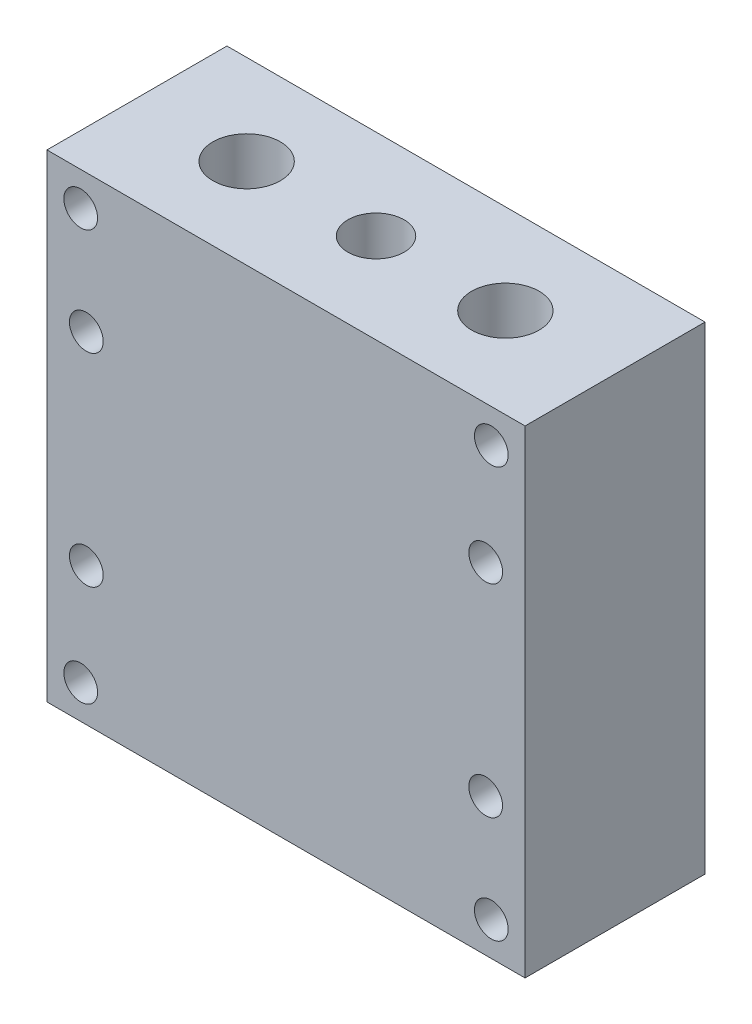
from build123d import *

# Parameters (mm, degrees)
SKETCH1_W           = 85
SKETCH1_H           = 85
BOSS_EXTRUDE1_DEPTH = 32
SKETCH2_R           = 3
CUT_EXTRUDE1_DEPTH  = 33
SKETCH3_R           = 5
SKETCH3_R_2         = 6
CUT_EXTRUDE2_DEPTH  = 86
SKETCH4_R           = 3
CUT_EXTRUDE3_DEPTH  = 33


with BuildPart() as part:
    # Sketch1 → Boss-Extrude1 (new body)
    with BuildSketch(Plane.XY):
        Rectangle(SKETCH1_W, SKETCH1_H)
    extrude(amount=BOSS_EXTRUDE1_DEPTH)

    # Sketch2 → Cut-Extrude1 (cut, through all)
    with BuildSketch(Plane.XY.offset(32)):
        with Locations((-36.5, 36.5)):
            Circle(SKETCH2_R)
        with Locations((36.5, 36.5)):
            Circle(SKETCH2_R)
        with Locations((36.5, -36.5)):
            Circle(SKETCH2_R)
        with Locations((-36.5, -36.5)):
            Circle(SKETCH2_R)
    extrude(amount=-CUT_EXTRUDE1_DEPTH, mode=Mode.SUBTRACT)

    # Sketch3 → Cut-Extrude2 (cut, through all)
    with BuildSketch(Plane(origin=(0, 42.5, 0), x_dir=(1, 0, 0), z_dir=(0, 1, 0))):
        with Locations((0, -16)):
            Circle(SKETCH3_R)
        with Locations((-23, -16)):
            Circle(SKETCH3_R_2)
        with Locations((23, -16)):
            Circle(SKETCH3_R_2)
    extrude(amount=-CUT_EXTRUDE2_DEPTH, mode=Mode.SUBTRACT)

    # Sketch4 → Cut-Extrude3 (cut, through all)
    with BuildSketch(Plane(origin=(0, 0, 0), x_dir=(-1, 0, 0), z_dir=(0, 0, -1))):
        with Locations((-35.5, 18)):
            Circle(SKETCH4_R)
        with Locations((-35.5, -18)):
            Circle(SKETCH4_R)
        with Locations((35.5, -18)):
            Circle(SKETCH4_R)
        with Locations((35.5, 18)):
            Circle(SKETCH4_R)
    extrude(amount=-CUT_EXTRUDE3_DEPTH, mode=Mode.SUBTRACT)


solid = part.part
